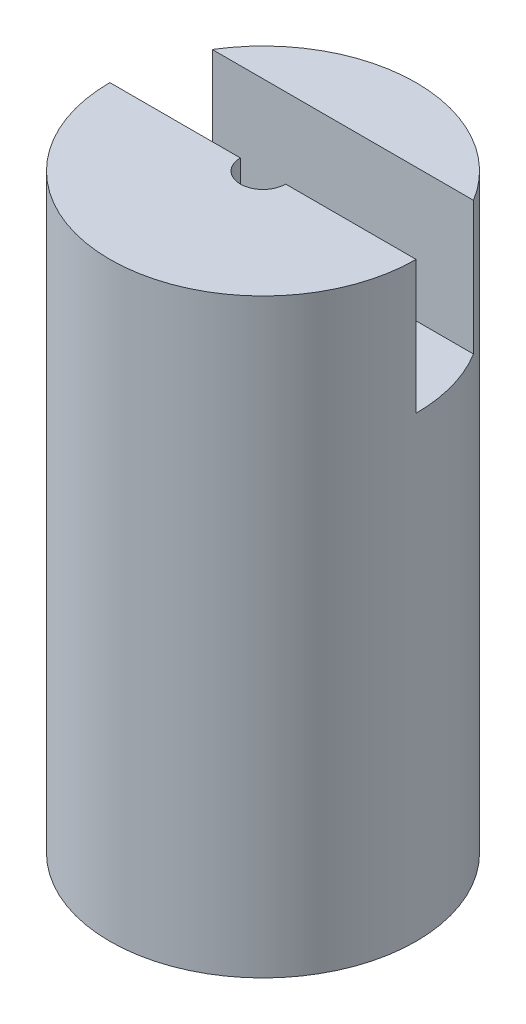
from build123d import *

# Parameters (mm, degrees)
SKETCH_2_W          = 43.624420354
SKETCH_2_H          = 30
CUT_EXTRUDE_1_DEPTH = 9


with BuildPart() as part:
    # Эскиз1 → Повернуть1 (revolve)
    with BuildSketch(Plane(origin=(0, 0, 0), x_dir=(0, 0, -1), z_dir=(1, 0, 0))):
        Polygon((2.25, 26.387863371), (0, 26.387863371), (0, -1.191709959), (17.25, -1.191709959), (17.25, 65.340178843), (2.55, 65.340178843), (2.55, 50.340178843), (2.25, 50.340178843), align=None)
    revolve(axis=Axis((0, 93.464109616, 0), (0, -1, 0)))

    # Эскиз2 → Вырез-Вытянуть1 (cut)
    with BuildSketch(Plane.XY):
        with Locations((0, 65.340178843)):
            Rectangle(SKETCH_2_W, SKETCH_2_H)
    extrude(amount=-CUT_EXTRUDE_1_DEPTH, mode=Mode.SUBTRACT)


solid = part.part
